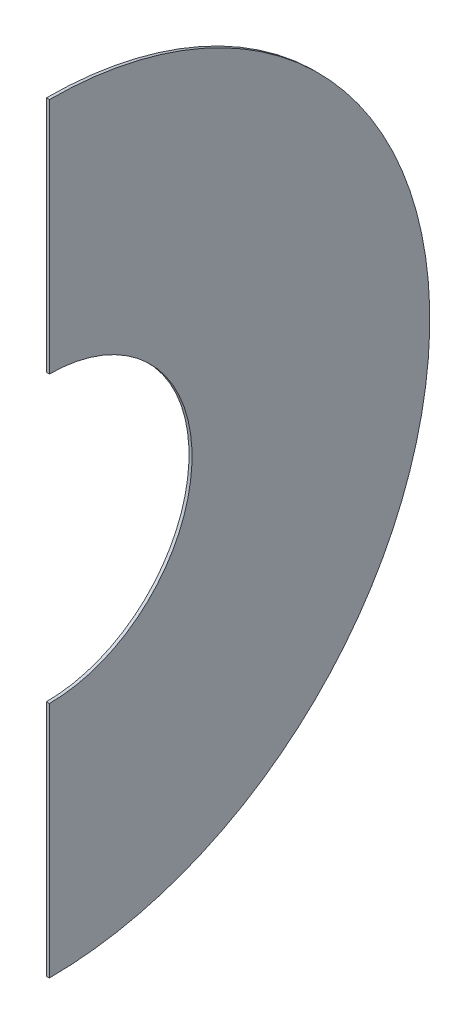
from build123d import *

# Parameters (mm, degrees)
BOSS_EXTRUDE1_DEPTH = 1.5875


with BuildPart() as part:
    # Sketch1 → Boss-Extrude1 (new body)
    with BuildSketch(Plane(origin=(0, 0, 0), x_dir=(0, 0, -1), z_dir=(1, 0, 0))):
        with BuildLine():
            ThreePointArc((200, 0), (141.421356237, 141.421356237), (0, 200))
            Line((0, 200), (0, 75))
            ThreePointArc((0, 75), (53.033008589, 53.033008589), (75, 0))
            ThreePointArc((75, 0), (53.033008589, -53.033008589), (0, -75))
            Line((0, -75), (0, -200))
            ThreePointArc((0, -200), (141.421356237, -141.421356237), (200, 0))
        make_face()
    extrude(amount=BOSS_EXTRUDE1_DEPTH)


solid = part.part
